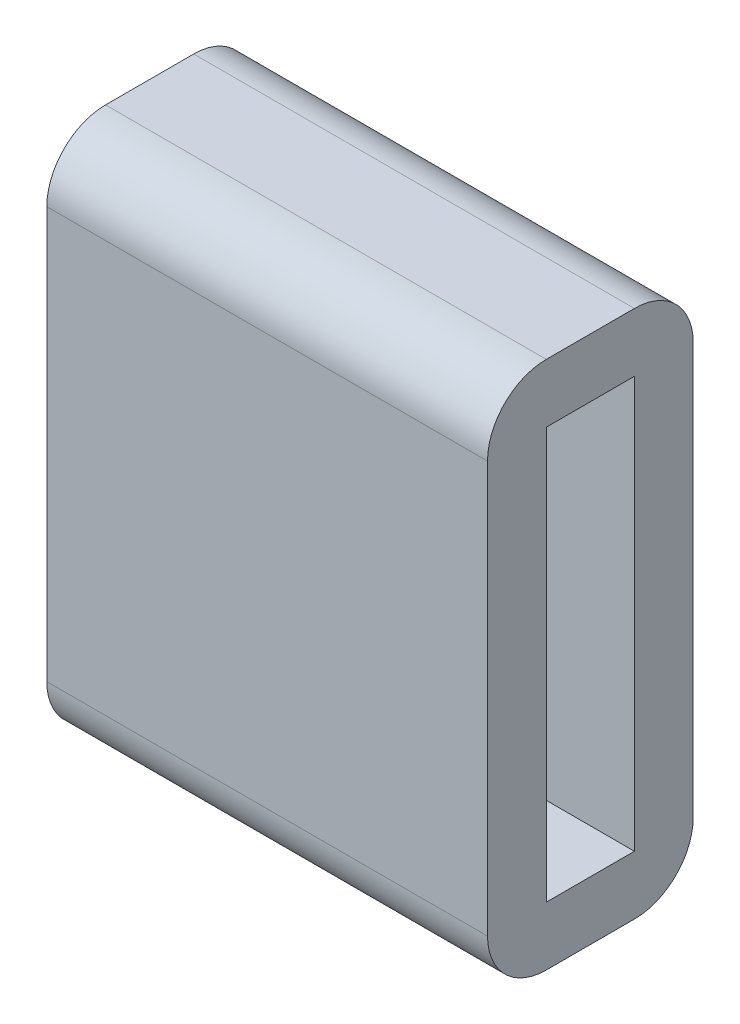
from build123d import *

# Parameters (mm, degrees)
SKICA1_W                 = 7.5
SKICA1_H                 = 9
P_IDAT_VYSUNUT_M1_DEPTH  = 3.5
ZAOBLIT1_R               = 1
SKICA2_W                 = 1.5
SKICA2_H                 = 7
ODEBRAT_VYSUNUT_M1_DEPTH = 5


with BuildPart() as part:
    # Skica1 → Přidat vysunutím1 (new body)
    with BuildSketch(Plane.XY):
        Rectangle(SKICA1_W, SKICA1_H)
    extrude(amount=P_IDAT_VYSUNUT_M1_DEPTH)

    # Zaoblit1
    zaoblit1_edges = [part.edges().sort_by_distance(p)[0] for p in [
        (0, -4.5, 3.5),
        (0, -4.5, 0),
        (0, 4.5, 0),
        (0, 4.5, 3.5),
    ]]
    fillet(zaoblit1_edges, radius=ZAOBLIT1_R)

    # Skica2 → Odebrat vysunutím1 (cut)
    with BuildSketch(Plane(origin=(3.75, 0, 0), x_dir=(0, 0, -1), z_dir=(1, 0, 0))):
        with Locations((-1.75, 0)):
            Rectangle(SKICA2_W, SKICA2_H)
    extrude(amount=-ODEBRAT_VYSUNUT_M1_DEPTH, mode=Mode.SUBTRACT)


solid = part.part
